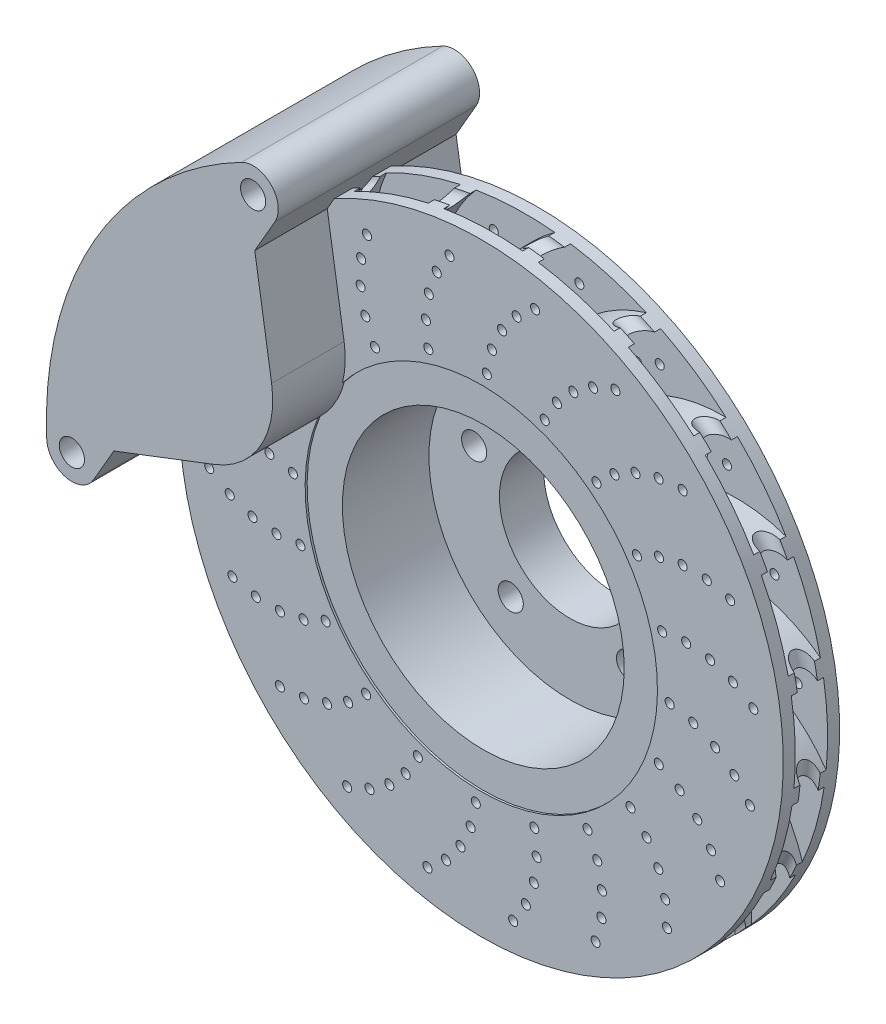
from build123d import *

# Parameters (mm, degrees)
SKETCH1_W           = 6
SKETCH1_H           = 62.5
SKETCH2_R           = 6.25
CUT_EXTRUDE2_DEPTH  = 67
SKETCH3_R           = 2.25
CUT_EXTRUDE7_DEPTH  = 50
BOSS_EXTRUDE3_DEPTH = 22
CIRPATTERN2_COUNT   = 20
SKETCH7_R           = 5
SKETCH8_R           = 6.25
BOSS_EXTRUDE4_DEPTH = 50


with BuildPart() as part:
    # Sketch1 → Revolve1 (revolve)
    with BuildSketch(Plane(origin=(0, 0, 0), x_dir=(0, 0, -1), z_dir=(1, 0, 0))):
        Polygon((-7.010369732, 87.5), (-7.010369732, 70), (35.989630268, 70), (35.989630268, 35), (57.989630268, 35), (57.989630268, 77.5), (-3.010369732, 77.5), (-3.010369732, 87.5), (-2.010369732, 87.5), (-2.010369732, 150), (-8.010369732, 150), (-8.010369732, 87.5), align=None)
        with Locations((16.989630268, 118.75)):
            Rectangle(SKETCH1_W, SKETCH1_H)
    revolve(axis=Axis((0, 0, 35.466468738), (0, 0, -1)))

    # Sketch2 → Cut-Extrude2 (cut, through all)
    with BuildSketch(Plane(origin=(0, 0, -57.989630268), x_dir=(-1, 0, 0), z_dir=(0, 0, -1))):
        with Locations((0, 50)):
            Circle(SKETCH2_R)
        with Locations((47.552825815, 15.450849719)):
            Circle(SKETCH2_R)
        with Locations((29.389262615, -40.450849719)):
            Circle(SKETCH2_R)
        with Locations((-29.389262615, -40.450849719)):
            Circle(SKETCH2_R)
        with Locations((-47.552825815, 15.450849719)):
            Circle(SKETCH2_R)
    extrude(amount=-CUT_EXTRUDE2_DEPTH, mode=Mode.SUBTRACT)

    # Sketch3 → Cut-Extrude7 (cut, symmetric)
    with BuildSketch(Plane.XY):
        with Locations((57.208532999, 74.092981624)):
            Circle(SKETCH3_R)
        with Locations((66.15026603, 82.058819139)):
            Circle(SKETCH3_R)
        with Locations((76.604167082, 87.900489254)):
            Circle(SKETCH3_R)
        with Locations((88.074637762, 91.341050153)):
            Circle(SKETCH3_R)
        with Locations((100.01788616, 92.217391777)):
            Circle(SKETCH3_R)
    cut_extrude7 = extrude(amount=CUT_EXTRUDE7_DEPTH, both=True, mode=Mode.SUBTRACT)

    # Sketch5 → Boss-Extrude3 (add)
    with BuildSketch(Plane.XY.offset(8.010369732)):
        with BuildLine():
            ThreePointArc((105.243937941, 106.881773594), (68.984611579, 100.93447811), (40.732963835, 77.440788072))
            ThreePointArc((40.732963835, 77.440788072), (38.4779342, 78.585613058), (36.190761347, 79.664790172))
            ThreePointArc((36.190761347, 79.664790172), (63.738847146, 103.945579642), (99.511499825, 112.238413222))
            ThreePointArc((99.511499825, 112.238413222), (102.412746866, 109.597578802), (105.243937941, 106.881773594))
        make_face()
    boss_extrude3 = extrude(amount=-BOSS_EXTRUDE3_DEPTH)

    # CirPattern2: Cut-Extrude7, Boss-Extrude3 ×20 about axis
    cirpattern2_axis = Axis((0, 0, 0), (0, 0, 1))
    for i in range(1, CIRPATTERN2_COUNT):
        add(cut_extrude7.rotate(cirpattern2_axis, i * 360 / CIRPATTERN2_COUNT), mode=Mode.SUBTRACT)
        add(boss_extrude3.rotate(cirpattern2_axis, i * 360 / CIRPATTERN2_COUNT))

    # Sketch7 → Cut-Revolve1 (revolve, cut)
    with BuildSketch(Plane(origin=(0, 0, 0), x_dir=(0, 0, -1), z_dir=(1, 0, 0))):
        with Locations((5.989630268, -150)):
            Circle(SKETCH7_R)
        with Locations((5.989630268, -87.5)):
            Circle(SKETCH7_R)
    revolve(axis=Axis((0, 0, -57.989630268), (0, 0, -1)), mode=Mode.SUBTRACT)

    # Sketch8 → Boss-Extrude4 (add, symmetric)
    with BuildSketch(Plane(origin=(0, 0, -5.989630268), x_dir=(-1, 0, 0), z_dir=(0, 0, -1))):
        with BuildLine():
            Line((66.515139784, 142.325582314), (76.515139784, 125.005074238))
            Line((76.515139784, 125.005074238), (68.135888715, 72.030462895))
            ThreePointArc((68.135888715, 72.030462895), (73.612159322, 42.5), (96.448155071, 22.992179089))
            Line((96.448155071, 22.992179089), (146.515139784, 3.761517708))
            Line((146.515139784, 3.761517708), (156.515139784, -13.558990368))
            ThreePointArc((156.515139784, -13.558990368), (170.311431473, -19.45079059), (179.828551162, -7.85443741))
            ThreePointArc((179.828551162, -7.85443741), (179.957132686, -3.928154202), (180, 0))
            ThreePointArc((180, 0), (155.884572681, 90), (90, 155.884572681))
            ThreePointArc((90, 155.884572681), (86.576685014, 157.811525599), (83.112133251, 159.663312337))
            ThreePointArc((83.112133251, 159.663312337), (68.310836962, 157.219421506), (66.515139784, 142.325582314))
        make_face()
        with Locations((167.340457331, -7.308990368)):
            Circle(SKETCH8_R, mode=Mode.SUBTRACT)
        with Locations((77.340457331, 148.575582314)):
            Circle(SKETCH8_R, mode=Mode.SUBTRACT)
    extrude(amount=BOSS_EXTRUDE4_DEPTH, both=True)


solid = part.part
